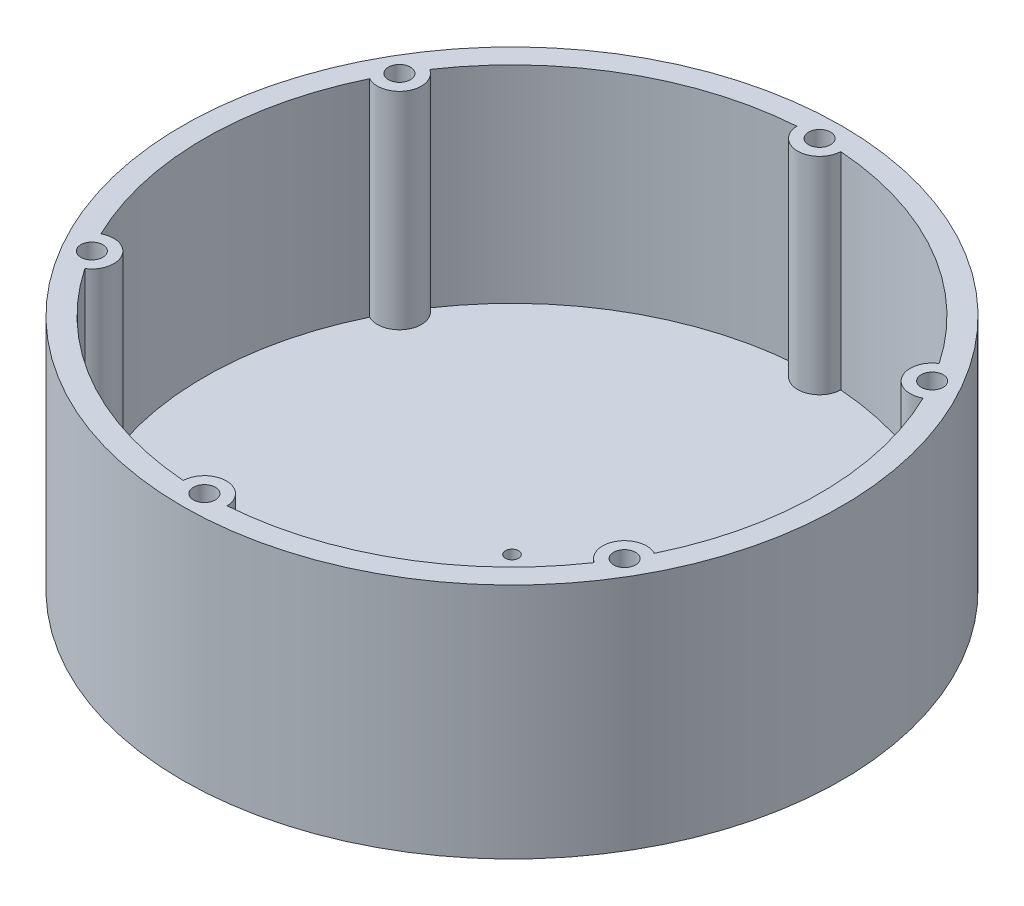
from build123d import *

# Parameters (mm, degrees)
SKETCH1_R            = 75
BOSS_EXTRUDE1_DEPTH  = 5
SKETCH2_R            = 75
SKETCH2_R_2          = 65
BOSS_EXTRUDE2_DEPTH  = 47
SKETCH3_R            = 2.5
CUT_EXTRUDE1_DEPTH   = 16
CUT_EXTRUDE2_REACH   = 54
SKETCH4_R            = 1.5
SKETCH6_R            = 60
CUT_EXTRUDE3_DEPTH   = 47
SKETCH7_R            = 75
SKETCH7_R_2          = 65
BOSS_EXTRUDE3_DEPTH  = 2
CUT_SWEEP1_PROFILE_R = 2.9


with BuildPart() as part:
    # Sketch1 → Boss-Extrude1 (new body)
    with BuildSketch(Plane(origin=(0, 0, 0), x_dir=(1, 0, 0), z_dir=(0, 1, 0))):
        Circle(SKETCH1_R)
    extrude(amount=BOSS_EXTRUDE1_DEPTH)

    # Sketch2 → Boss-Extrude2 (add)
    with BuildSketch(Plane(origin=(0, 5, 0), x_dir=(1, 0, 0), z_dir=(0, 1, 0))):
        Circle(SKETCH2_R)
        Circle(SKETCH2_R_2, mode=Mode.SUBTRACT)
    extrude(amount=BOSS_EXTRUDE2_DEPTH)

    # Sketch3 → Cut-Extrude1 (cut)
    with BuildSketch(Plane(origin=(0, 52, 0), x_dir=(1, 0, 0), z_dir=(0, 1, 0))):
        with Locations((0, 70)):
            Circle(SKETCH3_R)
        with Locations((60.621778265, 35)):
            Circle(SKETCH3_R)
        with Locations((60.621778265, -35)):
            Circle(SKETCH3_R)
        with Locations((0, -70)):
            Circle(SKETCH3_R)
        with Locations((-60.621778265, -35)):
            Circle(SKETCH3_R)
        with Locations((-60.621778265, 35)):
            Circle(SKETCH3_R)
    extrude(amount=-CUT_EXTRUDE1_DEPTH, mode=Mode.SUBTRACT)

    # Sketch4 → Cut-Extrude2 (cut, up to next)
    with BuildSketch(Plane.XZ, mode=Mode.PRIVATE) as cut_extrude2_sk1:
        Circle(SKETCH4_R)
    cut_extrude2_tool1 = extrude(cut_extrude2_sk1.sketch, amount=-CUT_EXTRUDE2_REACH, mode=Mode.PRIVATE) & part.part
    add(cut_extrude2_tool1.solids().sort_by_distance((0, 0, 0))[0], mode=Mode.SUBTRACT)

    # Sketch6 → Cut-Extrude3 (cut)
    with BuildSketch(Plane(origin=(0, 52, 0), x_dir=(1, 0, 0), z_dir=(0, 1, 0))):
        with BuildLine():
            ThreePointArc((-62.965535975, 30.583349709), (-70, 0), (-62.965535975, -30.583349709))
            ThreePointArc((-62.965535975, -30.583349709), (-56.291651246, -32.5), (-57.968725768, -39.238078863))
            ThreePointArc((-57.968725768, -39.238078863), (-35, -60.621778265), (-4.996810207, -69.821428571))
            ThreePointArc((-4.996810207, -69.821428571), (0, -65), (4.996810207, -69.821428571))
            ThreePointArc((4.996810207, -69.821428571), (35, -60.621778265), (57.968725768, -39.238078863))
            ThreePointArc((57.968725768, -39.238078863), (56.291651246, -32.5), (62.965535975, -30.583349709))
            ThreePointArc((62.965535975, -30.583349709), (70, 0), (62.965535975, 30.583349709))
            ThreePointArc((62.965535975, 30.583349709), (56.291651246, 32.5), (57.968725768, 39.238078863))
            ThreePointArc((57.968725768, 39.238078863), (35, 60.621778265), (4.996810207, 69.821428571))
            ThreePointArc((4.996810207, 69.821428571), (0, 65), (-4.996810207, 69.821428571))
            ThreePointArc((-4.996810207, 69.821428571), (-35, 60.621778265), (-57.968725768, 39.238078863))
            ThreePointArc((-57.968725768, 39.238078863), (-56.291651246, 32.5), (-62.965535975, 30.583349709))
        make_face()
        Circle(SKETCH6_R, mode=Mode.SUBTRACT)
    extrude(amount=-CUT_EXTRUDE3_DEPTH, mode=Mode.SUBTRACT)

    # Sketch7 → Boss-Extrude3 (add)
    with BuildSketch(Plane.XZ):
        Circle(SKETCH7_R)
        Circle(SKETCH7_R_2, mode=Mode.SUBTRACT)
    extrude(amount=BOSS_EXTRUDE3_DEPTH)

    # Cut-Sweep1: sweep along a path in Sketch8
    with BuildLine(Plane.XZ.offset(2)) as cut_sweep1_path:
        CenterArc((0, 0), 70, 0, 360)
    # Cut-Sweep1 profile (on start of the path) → Cut-Sweep1 (sweep, cut)
    with BuildSketch(Plane(origin=(70, -2, 0), x_dir=(1, 0, 0), z_dir=(0, 0, 1))):
        Circle(CUT_SWEEP1_PROFILE_R)
    sweep(path=cut_sweep1_path.line, mode=Mode.SUBTRACT)


solid = part.part
